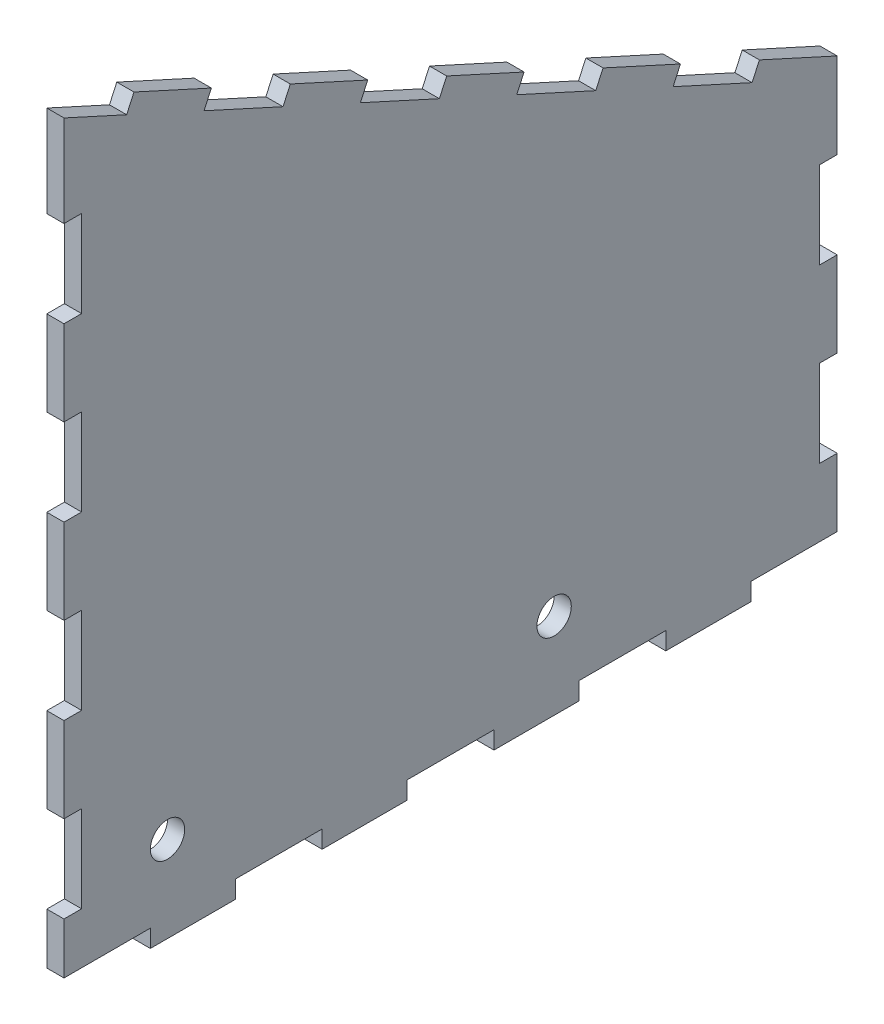
from build123d import *

# Parameters (mm, degrees)
BOSS_EXTRUDE1_DEPTH = 4
SKETCH2_W           = 20.2
SKETCH2_H           = 4.1
CUT_EXTRUDE1_DEPTH  = 5
LPATTERN1_COUNT     = 6
LPATTERN1_PITCH     = 40
SKETCH3_W           = 4.1
SKETCH3_H           = 20.2
CUT_EXTRUDE2_DEPTH  = 4
LPATTERN2_COUNT     = 4
LPATTERN2_PITCH     = 40
SKETCH4_W           = 4.1
SKETCH4_H           = 20.2
CUT_EXTRUDE3_DEPTH  = 4
LPATTERN3_COUNT     = 2
LPATTERN3_PITCH     = 40
CUT_EXTRUDE4_DEPTH  = 4
LPATTERN4_COUNT     = 6
LPATTERN4_PITCH     = 40
SKETCH6_R           = 4
CUT_EXTRUDE5_DEPTH  = 5


with BuildPart() as part:
    # Sketch1 → Boss-Extrude1 (new body)
    with BuildSketch(Plane(origin=(0, 0, 0), x_dir=(0, 0, -1), z_dir=(1, 0, 0))):
        Polygon((-60.155879739, 92), (119.844120261, 10), (119.844120261, -90), (-60.155879739, -90), align=None)
    extrude(amount=BOSS_EXTRUDE1_DEPTH)

    # Sketch2 → Cut-Extrude1 (cut, through all)
    with BuildSketch(Plane(origin=(4, 0, 0), x_dir=(0, 0, -1), z_dir=(1, 0, 0))):
        with Locations((-50.155879739, -87.95)):
            Rectangle(SKETCH2_W, SKETCH2_H)
    cut_extrude1 = extrude(amount=-CUT_EXTRUDE1_DEPTH, mode=Mode.SUBTRACT)

    # LPattern1: Cut-Extrude1 ×6
    with Locations(*[(0, 0, -i * LPATTERN1_PITCH) for i in range(1, LPATTERN1_COUNT)]):
        add(cut_extrude1, mode=Mode.SUBTRACT)

    # Sketch3 → Cut-Extrude2 (cut)
    with BuildSketch(Plane(origin=(4, 0, 0), x_dir=(0, 0, -1), z_dir=(1, 0, 0))):
        with Locations((-58.105879739, -63.9)):
            Rectangle(SKETCH3_W, SKETCH3_H)
    cut_extrude2 = extrude(amount=-CUT_EXTRUDE2_DEPTH, mode=Mode.SUBTRACT)

    # LPattern2: Cut-Extrude2 ×4
    with Locations(*[(0, i * LPATTERN2_PITCH, 0) for i in range(1, LPATTERN2_COUNT)]):
        add(cut_extrude2, mode=Mode.SUBTRACT)

    # Sketch4 → Cut-Extrude3 (cut)
    with BuildSketch(Plane(origin=(4, 0, 0), x_dir=(0, 0, -1), z_dir=(1, 0, 0))):
        with Locations((117.794120261, -60)):
            Rectangle(SKETCH4_W, SKETCH4_H)
    cut_extrude3 = extrude(amount=-CUT_EXTRUDE3_DEPTH, mode=Mode.SUBTRACT)

    # LPattern3: Cut-Extrude3 ×2
    with Locations(*[(0, i * LPATTERN3_PITCH, 0) for i in range(1, LPATTERN3_COUNT)]):
        add(cut_extrude3, mode=Mode.SUBTRACT)

    # Sketch5 → Cut-Extrude4 (cut)
    with BuildSketch(Plane(origin=(4, 0, 0), x_dir=(0, 0, -1), z_dir=(1, 0, 0))):
        Polygon((101.734724645, 18.249835781), (83.352323065, 26.624040945), (81.652608155, 22.892959436), (100.035009735, 14.518754272), align=None)
    cut_extrude4 = extrude(amount=-CUT_EXTRUDE4_DEPTH, mode=Mode.SUBTRACT)

    # LPattern4: Cut-Extrude4 ×6
    with Locations(*[Vector(0, 0.414564612, 0.91001988) * (i * LPATTERN4_PITCH) for i in range(1, LPATTERN4_COUNT)]):
        add(cut_extrude4, mode=Mode.SUBTRACT)

    # Sketch6 → Cut-Extrude5 (cut, through all)
    with BuildSketch(Plane(origin=(4, 0, 0), x_dir=(0, 0, -1), z_dir=(1, 0, 0))):
        with Locations((-36.055879739, -70)):
            Circle(SKETCH6_R)
        with Locations((53.944120261, -70)):
            Circle(SKETCH6_R)
    extrude(amount=-CUT_EXTRUDE5_DEPTH, mode=Mode.SUBTRACT)


solid = part.part
